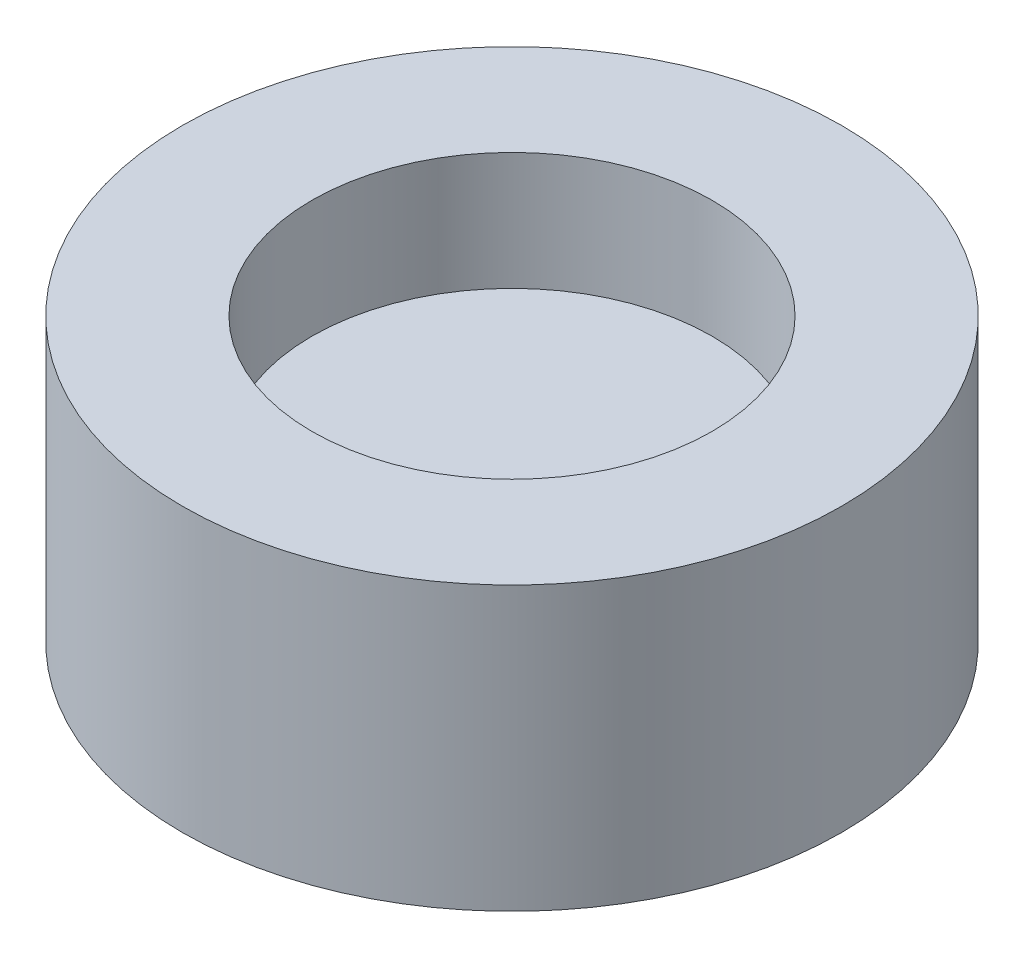
from build123d import *

# Parameters (mm, degrees)
SKETCH1_R           = 7
SKETCH1_R_2         = 5.25
BOSS_EXTRUDE1_DEPTH = 2.5
SKETCH2_R           = 7
BOSS_EXTRUDE2_DEPTH = 1
SKETCH3_R           = 7
SKETCH3_R_2         = 4.25
BOSS_EXTRUDE3_DEPTH = 2.5


with BuildPart() as part:
    # Sketch1 → Boss-Extrude1 (new body)
    with BuildSketch(Plane(origin=(0, 0, 0), x_dir=(1, 0, 0), z_dir=(0, 1, 0))):
        Circle(SKETCH1_R)
        Circle(SKETCH1_R_2, mode=Mode.SUBTRACT)
    extrude(amount=BOSS_EXTRUDE1_DEPTH)

    # Sketch2 → Boss-Extrude2 (add)
    with BuildSketch(Plane(origin=(0, 2.5, 0), x_dir=(1, 0, 0), z_dir=(0, 1, 0))):
        Circle(SKETCH2_R)
    extrude(amount=BOSS_EXTRUDE2_DEPTH)

    # Sketch3 → Boss-Extrude3 (add)
    with BuildSketch(Plane(origin=(0, 3.5, 0), x_dir=(1, 0, 0), z_dir=(0, 1, 0))):
        Circle(SKETCH3_R)
        Circle(SKETCH3_R_2, mode=Mode.SUBTRACT)
    extrude(amount=BOSS_EXTRUDE3_DEPTH)


solid = part.part
